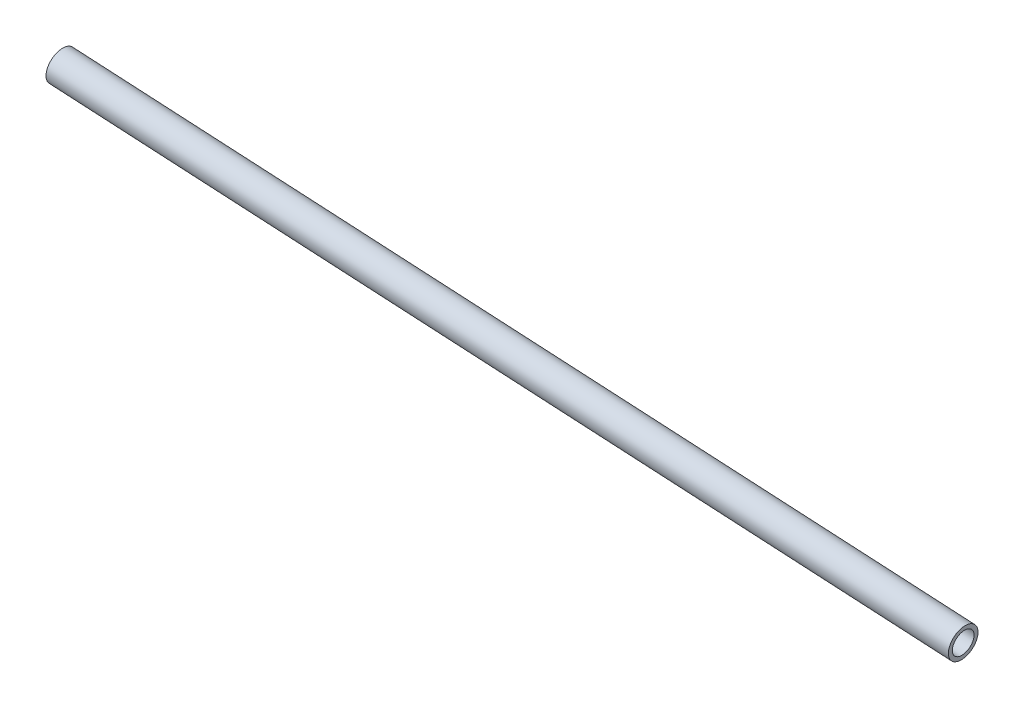
from build123d import *

# Parameters (mm, degrees)
SKETCH1_R                               = 9.525
SKETCH1_R_2                             = 6.985
PIPE_STANDARD_S40_PIPE_1_SCH_40_1_DEPTH = 547.192133839


with BuildPart() as part:
    # Sketch1 → Pipe standard s40 PIPE 1 SCH 40(1) (new body)
    with BuildSketch(Plane(origin=(192.7225, -0.197973407, -0.1143), x_dir=(-0.024725022684493236, 0.09126186565178956, -0.9955199370836357), z_dir=(0.9955199370836357, -0.08866086485698889, -0.032852791537474245))):
        Circle(SKETCH1_R)
        Circle(SKETCH1_R_2, mode=Mode.SUBTRACT)
    extrude(amount=PIPE_STANDARD_S40_PIPE_1_SCH_40_1_DEPTH)


solid = part.part
